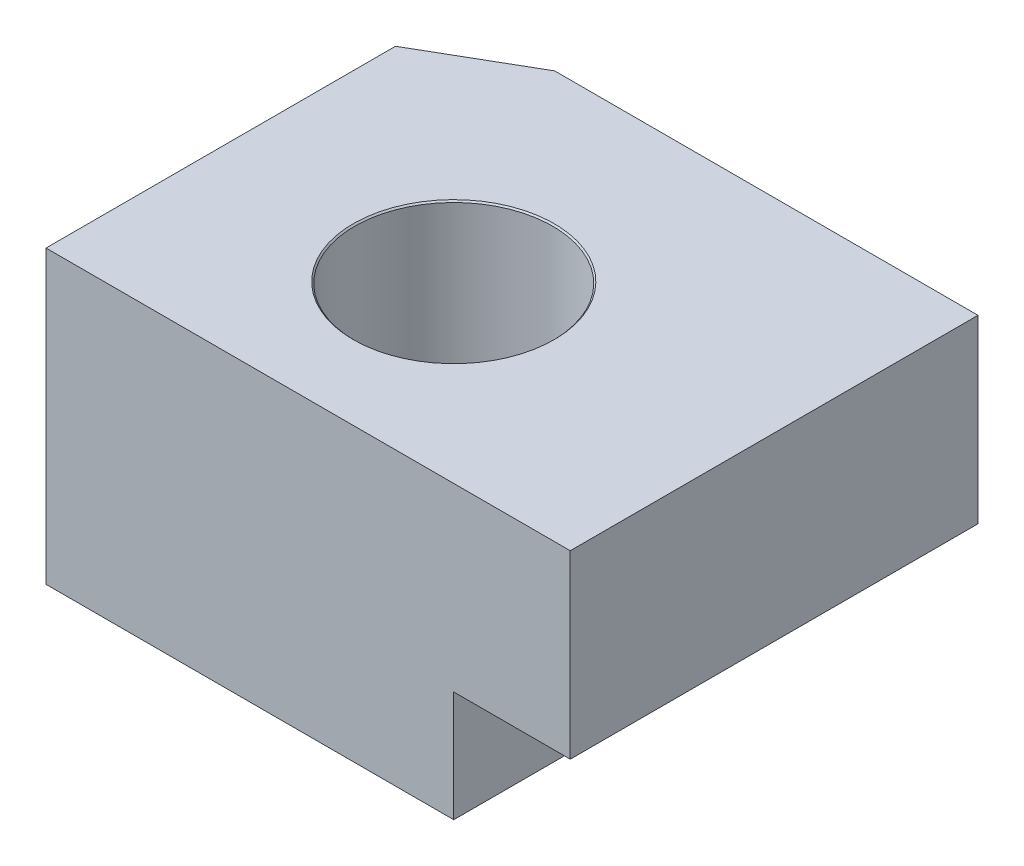
from build123d import *

# Parameters (mm, degrees)
EXTRUDE_1_DEPTH = 7
CHAMFER_1_SIZE  = 1
CHAMFER_1_SIZE2 = 1.732050808


with BuildPart() as part:
    # Эскиз1 → Бобышка-Вытянуть1 (new body)
    with BuildSketch(Plane.XY):
        Polygon((0, 0), (0, 1.9), (2, 1.9), (2, 5), (-7, 5), (-7, 0), align=None)
    extrude(amount=EXTRUDE_1_DEPTH)

    # Эскиз4 → Отверстие с зазором M31 (revolve, cut)
    with BuildSketch(Plane(origin=(-3, 5, 4), x_dir=(0, 0, 1), z_dir=(1, 0, 0))):
        Polygon((0, 0), (0, 5), (1.725, 5), (1.7, 4.975), (1.7, 0.025), (1.725, 0), align=None)
    revolve(axis=Axis((-3, 11.35, 4), (0, -1, 0)), mode=Mode.SUBTRACT)

    # Фаска1
    chamfer_1_edges = [part.edges().sort_by_distance(p)[0] for p in [
        (-7, 2.5, 0),
    ]]
    chamfer_1_side = [part.faces().sort_by_distance(p)[0] for p in [
        (-7, 2.5, 3.5),
    ]]
    chamfer(chamfer_1_edges, length=CHAMFER_1_SIZE, length2=CHAMFER_1_SIZE2, reference=chamfer_1_side[0])


solid = part.part
